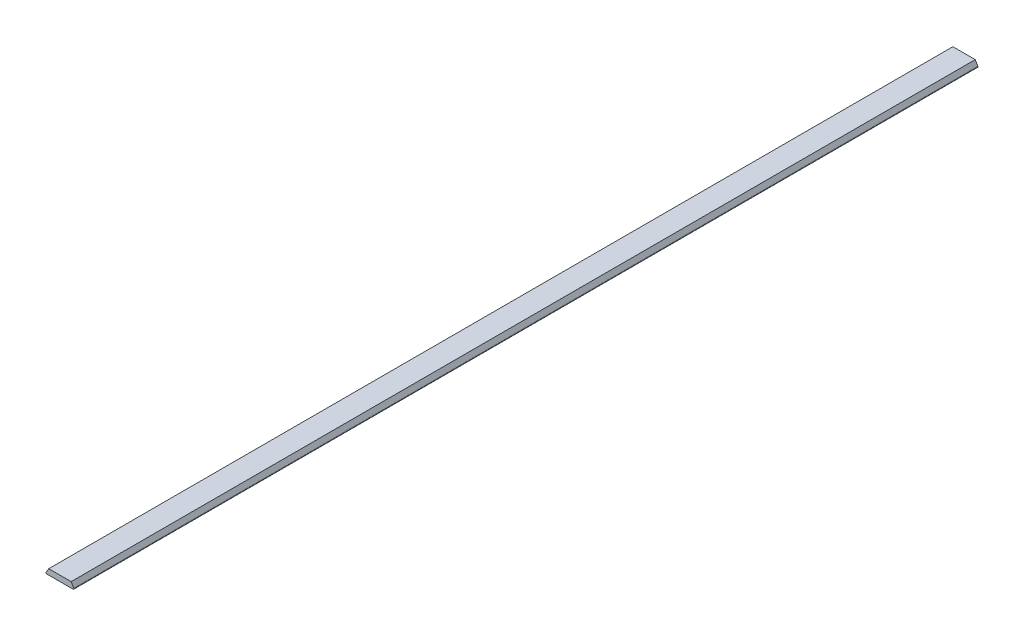
from build123d import *

# Parameters (mm, degrees)
BOSS_EXTRUDE1_DEPTH = 889


with BuildPart() as part:
    # Sketch1 → Boss-Extrude1 (new body)
    with BuildSketch(Plane.XY):
        with BuildLine():
            Line((0, 5.5), (-2.596847634, 1.133357313))
            ThreePointArc((-2.596847634, 1.133357313), (-2.604153044, 0.379202201), (-1.952225907, 0))
            Line((-1.952225907, 0), (0, 0))
            Line((0, 0), (22, 0))
            Line((22, 0), (23.952225907, 0))
            ThreePointArc((23.952225907, 0), (24.604153044, 0.379202201), (24.596847634, 1.133357313))
            Line((24.596847634, 1.133357313), (22, 5.5))
            Line((22, 5.5), (0, 5.5))
        make_face()
    extrude(amount=BOSS_EXTRUDE1_DEPTH)


solid = part.part
